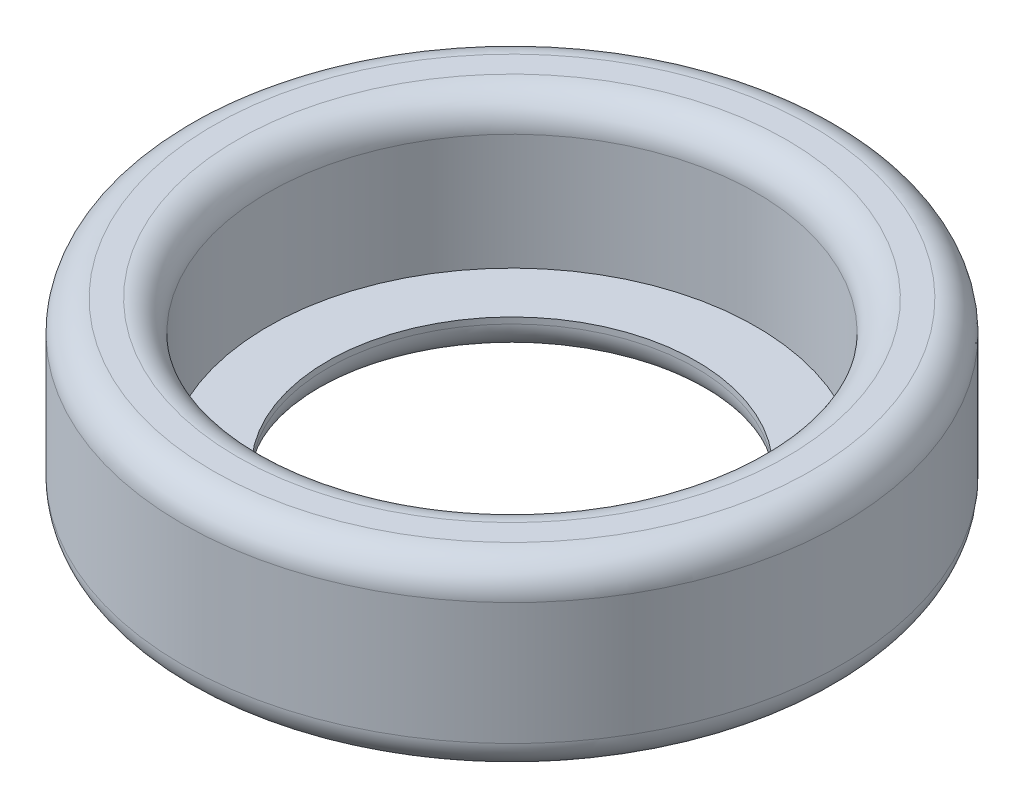
from build123d import *

# Parameters (mm, degrees)
ESQUISSE1_R             = 27
ESQUISSE1_R_2           = 15.1
BOSS_EXTRU_1_DEPTH      = 15
ESQUISSE2_R             = 20
ENL_V_MAT_EXTRU_1_DEPTH = 12
CONG_1_R                = 2.5


with BuildPart() as part:
    # Esquisse1 → Boss.-Extru.1 (new body)
    with BuildSketch(Plane(origin=(0, 0, 0), x_dir=(1, 0, 0), z_dir=(0, 1, 0))):
        with Locations(Location((0, 0, 0), (0, 0, 270))):  # turned: the seam where the file's is
            Circle(ESQUISSE1_R)
        with Locations(Location((0, 0, 0), (0, 0, 270))):  # turned: the seam where the file's is
            Circle(ESQUISSE1_R_2, mode=Mode.SUBTRACT)
    extrude(amount=BOSS_EXTRU_1_DEPTH)

    # Esquisse2 → Enlèv. mat.-Extru.1 (cut)
    with BuildSketch(Plane(origin=(0, 15, 0), x_dir=(-1, 0, 0), z_dir=(0, 1, 0))):
        with Locations(Location((0, 0, 0), (0, 0, 90))):  # turned: the seam where the file's is
            Circle(ESQUISSE2_R)
    extrude(amount=-ENL_V_MAT_EXTRU_1_DEPTH, mode=Mode.SUBTRACT)

    # Congé1
    cong_1_edges = [part.edges().sort_by_distance(p)[0] for p in [
        (0, 15, -20),
        (0, 0, -27),
        (0, 15, -27),
        (0, 0, -15.1),
    ]]
    fillet(cong_1_edges, radius=CONG_1_R)


solid = part.part
